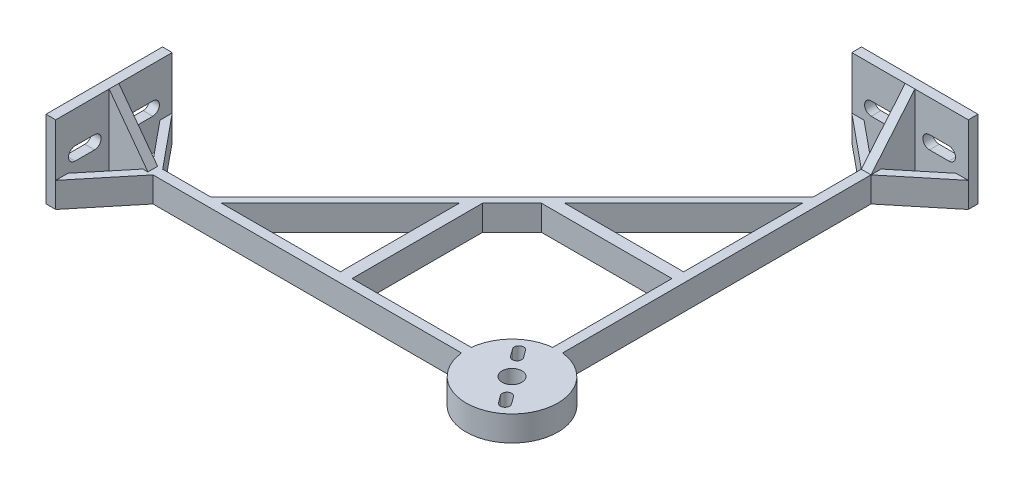
from build123d import *

# Parameters (mm, degrees)
SKETCH1_R                       = 15
BOSS_EXTRUDE2_DEPTH             = 8.255
BOSS_EXTRUDE3_DEPTH             = 8.255
SKETCH5_R                       = 3.249999977
CUT_EXTRUDE3_DEPTH              = 63.5
SKETCH7_W                       = 3.175
SKETCH7_H                       = 25.4
BOSS_EXTRUDE5_DEPTH             = 19.05
CUT_EXTRUDE6_DEPTH              = 149.35
CIRPATTERN2_COUNT               = 2
CIRPATTERN2_ANGLE               = 90
CIRPATTERN3_COUNT               = 2
CIRPATTERN3_ANGLE               = 90
BOSS_EXTRUDE6_DEPTH             = 8.255
BOSS_EXTRUDE7_REACH             = 21.05
BOSS_EXTRUDE7_DIRECTION_2_REACH = 135.35
BOSS_EXTRUDE8_REACH             = 21.05
BOSS_EXTRUDE8_DIRECTION_2_REACH = 135.35
BOSS_EXTRUDE9_REACH             = 133.763
SKETCH19_W                      = 3.81
SKETCH19_H                      = 8.255
BOSS_EXTRUDE10_REACH            = 133.763
SKETCH20_W                      = 3.81
SKETCH20_H                      = 8.255


with BuildPart() as part:
    # Sketch1 → Boss-Extrude2 (new body)
    with BuildSketch(Plane(origin=(0, 0, 0), x_dir=(1, 0, 0), z_dir=(0, 1, 0))):
        Circle(SKETCH1_R)
    extrude(amount=BOSS_EXTRUDE2_DEPTH)

    # Sketch1_6 → Boss-Extrude3 (add)
    with BuildSketch(Plane(origin=(0, 0, 0), x_dir=(1, 0, 0), z_dir=(0, 1, 0))):
        with BuildLine():
            Line((-1.5875, 130.175), (-1.5875, 14.915758236))
            ThreePointArc((-1.5875, 14.915758236), (0, 15), (1.5875, 14.915758236))
            Line((1.5875, 14.915758236), (1.5875, 130.175))
            Line((1.5875, 130.175), (-1.5875, 130.175))
        make_face()
        with BuildLine():
            ThreePointArc((-14.915758236, -1.5875), (-15, 0), (-14.915758236, 1.5875))
            Line((-14.915758236, 1.5875), (-130.175, 1.5875))
            Line((-130.175, 1.5875), (-130.175, -1.5875))
            Line((-130.175, -1.5875), (-14.915758236, -1.5875))
        make_face()
    extrude(amount=BOSS_EXTRUDE3_DEPTH)

    # Sketch5 → Cut-Extrude3 (cut)
    with BuildSketch(Plane(origin=(0, 8.255, 0), x_dir=(1, 0, 0), z_dir=(0, 1, 0))):
        Circle(SKETCH5_R)
        with BuildLine():
            Line((-5.908712478, 5.423058993), (-7.721732332, 7.873214705))
            ThreePointArc((-7.721732332, 7.873214705), (-7.403164404, 10.004802487), (-5.271576621, 9.686234559))
            Line((-5.271576621, 9.686234559), (-3.458556767, 7.236078848))
            ThreePointArc((-3.458556767, 7.236078848), (-3.777124696, 5.104491065), (-5.908712478, 5.423058993))
        make_face()
        with BuildLine():
            Line((3.458556767, -7.236078848), (5.271576621, -9.686234559))
            ThreePointArc((5.271576621, -9.686234559), (7.403164404, -10.004802487), (7.721732332, -7.873214705))
            Line((7.721732332, -7.873214705), (5.908712478, -5.423058993))
            ThreePointArc((5.908712478, -5.423058993), (3.777124696, -5.104491065), (3.458556767, -7.236078848))
        make_face()
    extrude(amount=-CUT_EXTRUDE3_DEPTH, mode=Mode.SUBTRACT)

    # Sketch7 → Boss-Extrude5 (add, symmetric)
    with BuildSketch(Plane(origin=(0, 0, 0), x_dir=(0, 0, -1), z_dir=(1, 0, 0))):
        with Locations((131.7625, 12.7)):
            Rectangle(SKETCH7_W, SKETCH7_H)
    boss_extrude5 = extrude(amount=BOSS_EXTRUDE5_DEPTH, both=True)

    # Sketch12 → Cut-Extrude6 (cut, through all)
    with BuildSketch(Plane(origin=(0, 0, -133.35), x_dir=(-1, 0, 0), z_dir=(0, 0, -1))):
        with BuildLine():
            Line((-6.35, 10.541), (-12.7, 10.541))
            ThreePointArc((-12.7, 10.541), (-14.859, 12.7), (-12.7, 14.859))
            Line((-12.7, 14.859), (-6.35, 14.859))
            ThreePointArc((-6.35, 14.859), (-4.191, 12.7), (-6.35, 10.541))
        make_face()
        with BuildLine():
            Line((6.35, 14.859), (12.7, 14.859))
            ThreePointArc((12.7, 14.859), (14.859, 12.7), (12.7, 10.541))
            Line((12.7, 10.541), (6.35, 10.541))
            ThreePointArc((6.35, 10.541), (4.191, 12.7), (6.35, 14.859))
        make_face()
    cut_extrude6 = extrude(amount=-CUT_EXTRUDE6_DEPTH, mode=Mode.SUBTRACT)

    # CirPattern2: Boss-Extrude5 ×2 about axis
    cirpattern2_axis = Axis((0, 0, 0), (0, 1, 0))
    for i in range(1, CIRPATTERN2_COUNT):
        add(boss_extrude5.rotate(cirpattern2_axis, i * CIRPATTERN2_ANGLE / (CIRPATTERN2_COUNT - 1)))

    # CirPattern3: Cut-Extrude6 ×2 about axis
    cirpattern3_axis = Axis((0, 0, 0), (0, 1, 0))
    for i in range(1, CIRPATTERN3_COUNT):
        add(cut_extrude6.rotate(cirpattern3_axis, i * CIRPATTERN3_ANGLE / (CIRPATTERN3_COUNT - 1)), mode=Mode.SUBTRACT)

    # Sketch13 → Boss-Extrude6 (add)
    with BuildSketch(Plane.XZ):
        Polygon((-96.628948776, -1.5875), (-1.5875, -96.628948776), (-1.5875, -100.221051224), (-100.221051224, -1.5875), align=None)
        Polygon((-19.05, -130.175), (-1.5875, -115.831500599), (-1.5875, -119.118499401), (-15.048241783, -130.175), align=None)
        Polygon((19.05, -130.175), (1.5875, -115.831500599), (1.5875, -119.118499401), (15.048241783, -130.175), align=None)
        Polygon((-119.118499401, 1.5875), (-130.175, 15.048241783), (-130.175, 19.05), (-115.831500599, 1.5875), align=None)
        Polygon((-119.118499401, -1.5875), (-130.175, -15.048241783), (-130.175, -19.05), (-115.831500599, -1.5875), align=None)
    extrude(amount=-BOSS_EXTRUDE6_DEPTH)

    # Boss-Extrude7: up to this face of the body (flat: up to its plane)
    boss_extrude7_end = Plane(part.part.faces().sort_by_distance((-124.646749701, 4.1275, 1.5875))[0])
    # Sketch14 → Boss-Extrude7 (add, up to the picked face)
    with BuildSketch(Plane.XY, mode=Mode.PRIVATE) as boss_extrude7_sk1:
        Polygon((-130.175, 25.4), (-117.475, 8.255), (-130.175, 8.255), align=None)
    boss_extrude7_tool1 = split(extrude(boss_extrude7_sk1.sketch, amount=BOSS_EXTRUDE7_REACH, mode=Mode.PRIVATE), bisect_by=boss_extrude7_end, keep=Keep.BOTH, mode=Mode.PRIVATE)
    add(boss_extrude7_tool1.solids().sort_by_distance((-125.941667, 13.97, 0))[0])

    # Boss-Extrude7 direction 2: up to this face of the body (flat: up to its plane)
    boss_extrude7_direction_2_end = Plane(part.part.faces().sort_by_distance((-124.646749701, 4.1275, -1.5875))[0])
    # Sketch14 → Boss-Extrude7 direction 2 (add, up to the picked face)
    with BuildSketch(Plane.XY, mode=Mode.PRIVATE) as boss_extrude7_direction_2_sk1:
        Polygon((-130.175, 25.4), (-117.475, 8.255), (-130.175, 8.255), align=None)
    boss_extrude7_direction_2_tool1 = split(extrude(boss_extrude7_direction_2_sk1.sketch, amount=-BOSS_EXTRUDE7_DIRECTION_2_REACH, mode=Mode.PRIVATE), bisect_by=boss_extrude7_direction_2_end, keep=Keep.BOTH, mode=Mode.PRIVATE)
    add(boss_extrude7_direction_2_tool1.solids().sort_by_distance((-125.941667, 13.97, 0))[0])

    # Boss-Extrude8: up to this face of the body (flat: up to its plane)
    boss_extrude8_end = Plane(part.part.faces().sort_by_distance((1.5875, 4.1275, -65.373629417))[0])
    # Sketch15 → Boss-Extrude8 (add, up to the picked face)
    with BuildSketch(Plane(origin=(0, 0, 0), x_dir=(0, 0, -1), z_dir=(1, 0, 0)), mode=Mode.PRIVATE) as boss_extrude8_sk1:
        Polygon((130.175, 25.4), (115.831500599, 8.255), (130.175, 8.255), align=None)
    boss_extrude8_tool1 = split(extrude(boss_extrude8_sk1.sketch, amount=BOSS_EXTRUDE8_REACH, mode=Mode.PRIVATE), bisect_by=boss_extrude8_end, keep=Keep.BOTH, mode=Mode.PRIVATE)
    add(boss_extrude8_tool1.solids().sort_by_distance((0, 13.97, -125.393834))[0])

    # Boss-Extrude8 direction 2: up to this face of the body (flat: up to its plane)
    boss_extrude8_direction_2_end = Plane(part.part.faces().sort_by_distance((-1.5875, 4.1275, -108.026275912))[0])
    # Sketch15 → Boss-Extrude8 direction 2 (add, up to the picked face)
    with BuildSketch(Plane(origin=(0, 0, 0), x_dir=(0, 0, -1), z_dir=(1, 0, 0)), mode=Mode.PRIVATE) as boss_extrude8_direction_2_sk1:
        Polygon((130.175, 25.4), (115.831500599, 8.255), (130.175, 8.255), align=None)
    boss_extrude8_direction_2_tool1 = split(extrude(boss_extrude8_direction_2_sk1.sketch, amount=-BOSS_EXTRUDE8_DIRECTION_2_REACH, mode=Mode.PRIVATE), bisect_by=boss_extrude8_direction_2_end, keep=Keep.BOTH, mode=Mode.PRIVATE)
    add(boss_extrude8_direction_2_tool1.solids().sort_by_distance((0, 13.97, -125.393834))[0])

    # Sketch19 → Boss-Extrude9 (add, up to next)
    with BuildSketch(Plane.ZY.offset(1.5875), mode=Mode.PRIVATE) as boss_extrude9_sk1:
        with Locations((-55.809758236, 4.1275)):
            Rectangle(SKETCH19_W, SKETCH19_H)
    boss_extrude9_tool1 = extrude(boss_extrude9_sk1.sketch, amount=BOSS_EXTRUDE9_REACH, mode=Mode.PRIVATE) - part.part
    add(boss_extrude9_tool1.solids().sort_by_distance((-1.5875, 4.1275, -55.809758))[0])

    # Sketch20 → Boss-Extrude10 (add, up to next)
    with BuildSketch(Plane(origin=(0, 0, -1.5875), x_dir=(-1, 0, 0), z_dir=(0, 0, -1)), mode=Mode.PRIVATE) as boss_extrude10_sk1:
        with Locations((55.809758236, 4.1275)):
            Rectangle(SKETCH20_W, SKETCH20_H)
    boss_extrude10_tool1 = extrude(boss_extrude10_sk1.sketch, amount=BOSS_EXTRUDE10_REACH, mode=Mode.PRIVATE) - part.part
    add(boss_extrude10_tool1.solids().sort_by_distance((-55.809758, 4.1275, -1.5875))[0])


solid = part.part
